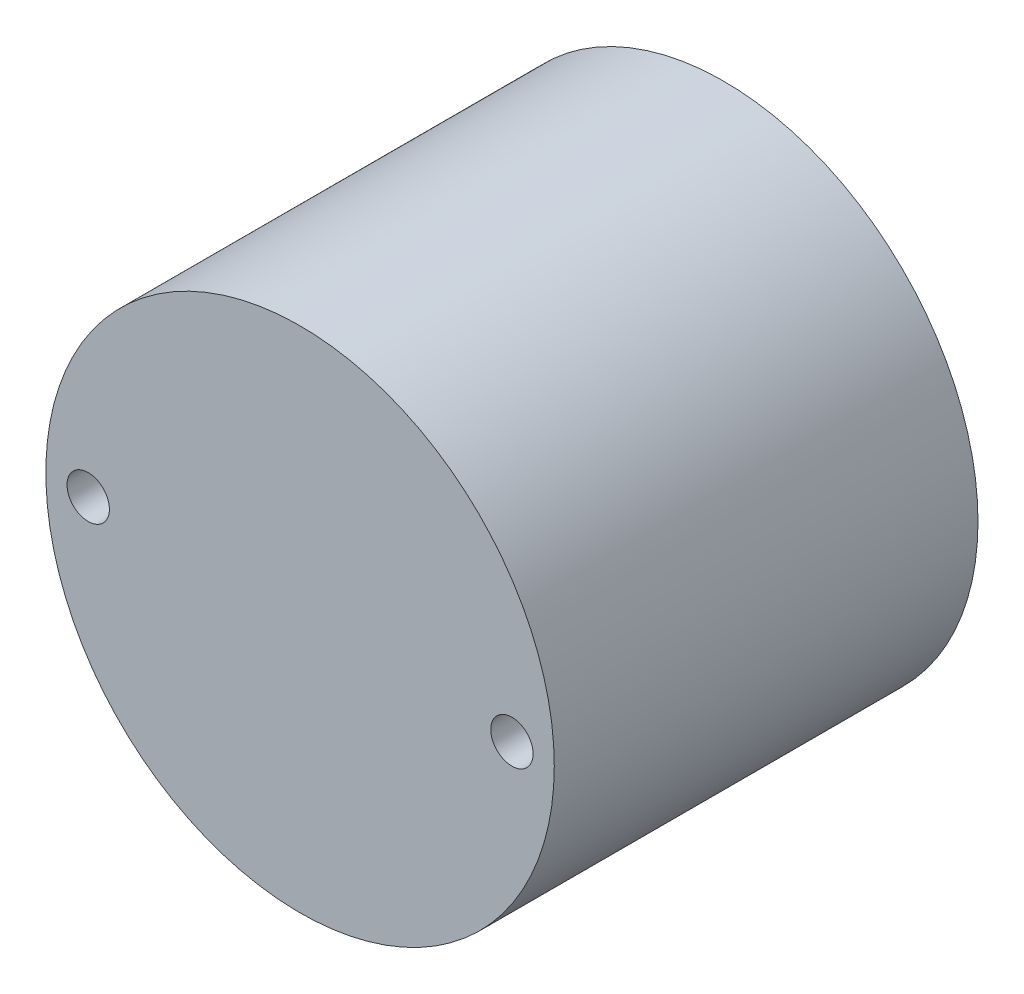
from build123d import *

# Parameters (mm, degrees)
SKETCH2_R           = 6
SKETCH2_R_2         = 0.5
BOSS_EXTRUDE2_DEPTH = 10


with BuildPart() as part:
    # Sketch2 → Boss-Extrude2 (new body)
    with BuildSketch(Plane.XY):
        Circle(SKETCH2_R)
        with Locations((-5, 0)):
            Circle(SKETCH2_R_2, mode=Mode.SUBTRACT)
        with Locations((5, 0)):
            Circle(SKETCH2_R_2, mode=Mode.SUBTRACT)
    extrude(amount=BOSS_EXTRUDE2_DEPTH)


solid = part.part
